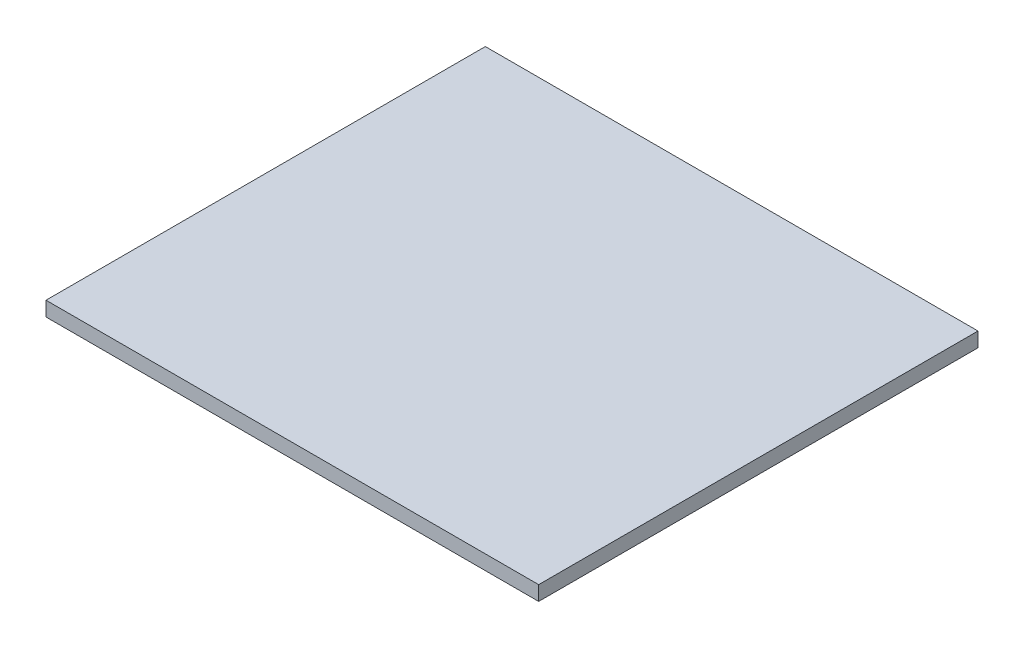
from build123d import *

# Parameters (mm, degrees)
CROQUIS1_W              = 923.8
CROQUIS1_H              = 823.8
SALIENTE_EXTRUIR1_DEPTH = 1.9
CROQUIS2_W              = 923.8
CROQUIS2_H              = 823.8
CROQUIS2_W_2            = 920
CROQUIS2_H_2            = 820
SALIENTE_EXTRUIR2_DEPTH = 25.4


with BuildPart() as part:
    # Croquis1 → Saliente-Extruir1 (new body)
    with BuildSketch(Plane(origin=(0, 0, 0), x_dir=(1, 0, 0), z_dir=(0, 1, 0))):
        Rectangle(CROQUIS1_W, CROQUIS1_H)
    extrude(amount=SALIENTE_EXTRUIR1_DEPTH)

    # Croquis2 → Saliente-Extruir2 (add)
    with BuildSketch(Plane.XZ):
        Rectangle(CROQUIS2_W, CROQUIS2_H)
        Rectangle(CROQUIS2_W_2, CROQUIS2_H_2, mode=Mode.SUBTRACT)
    extrude(amount=SALIENTE_EXTRUIR2_DEPTH)


solid = part.part
